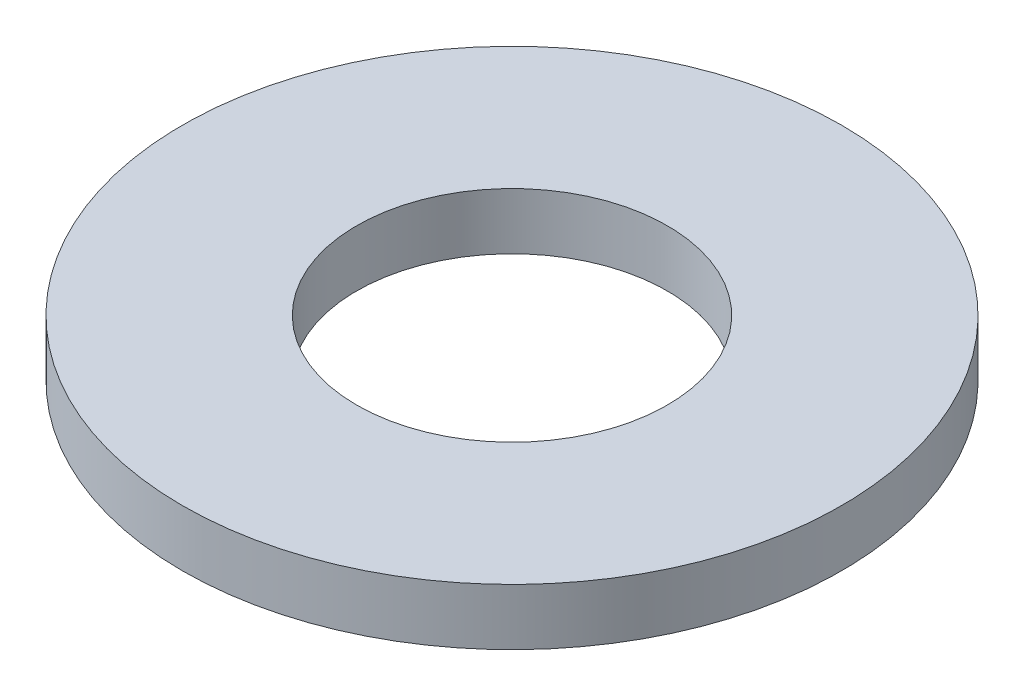
from build123d import *

# Parameters (mm, degrees)
SKETCH1_R           = 3.5
SKETCH1_R_2         = 1.65
BOSS_EXTRUDE1_DEPTH = 0.6


with BuildPart() as part:
    # Sketch1 → Boss-Extrude1 (new body)
    with BuildSketch(Plane(origin=(0, 0, 0), x_dir=(1, 0, 0), z_dir=(0, 1, 0))):
        Circle(SKETCH1_R)
        Circle(SKETCH1_R_2, mode=Mode.SUBTRACT)
    extrude(amount=BOSS_EXTRUDE1_DEPTH)


solid = part.part
